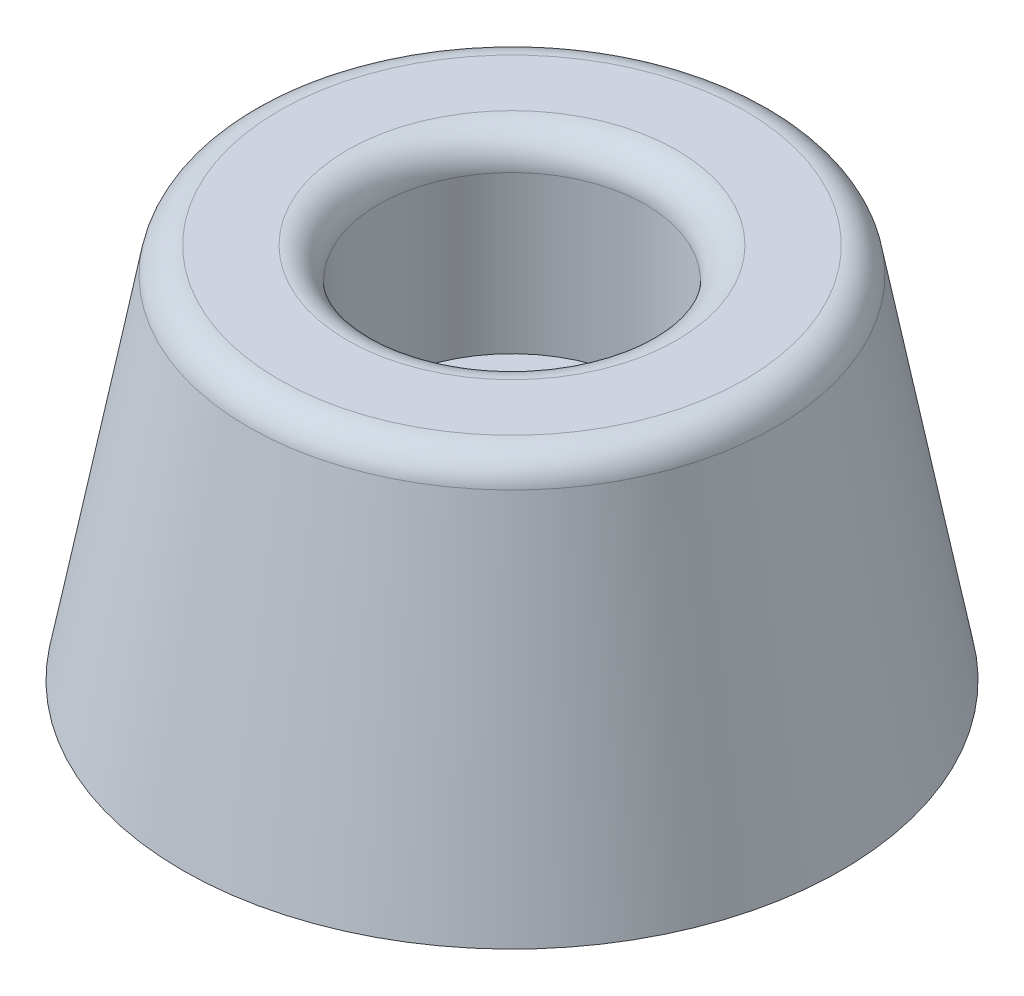
from build123d import *

# Parameters (mm, degrees)
FILLET1_R = 1


with BuildPart() as part:
    # Sketch1 → Revolve1 (revolve)
    with BuildSketch(Plane(origin=(0, 0, 0), x_dir=(0, 0, -1), z_dir=(1, 0, 0))):
        Polygon((2.1, 6), (4.25, 6), (4.25, 12), (8.25, 12), (10.5, 0), (2.1, 0), align=None)
    revolve(axis=Axis((0, 0, 0), (0, 1, 0)))

    # Fillet1
    fillet1_edges = [part.edges().sort_by_distance(p)[0] for p in [
        (0, 12, 8.25),
        (0, 12, 4.25),
    ]]
    fillet(fillet1_edges, radius=FILLET1_R)


solid = part.part
